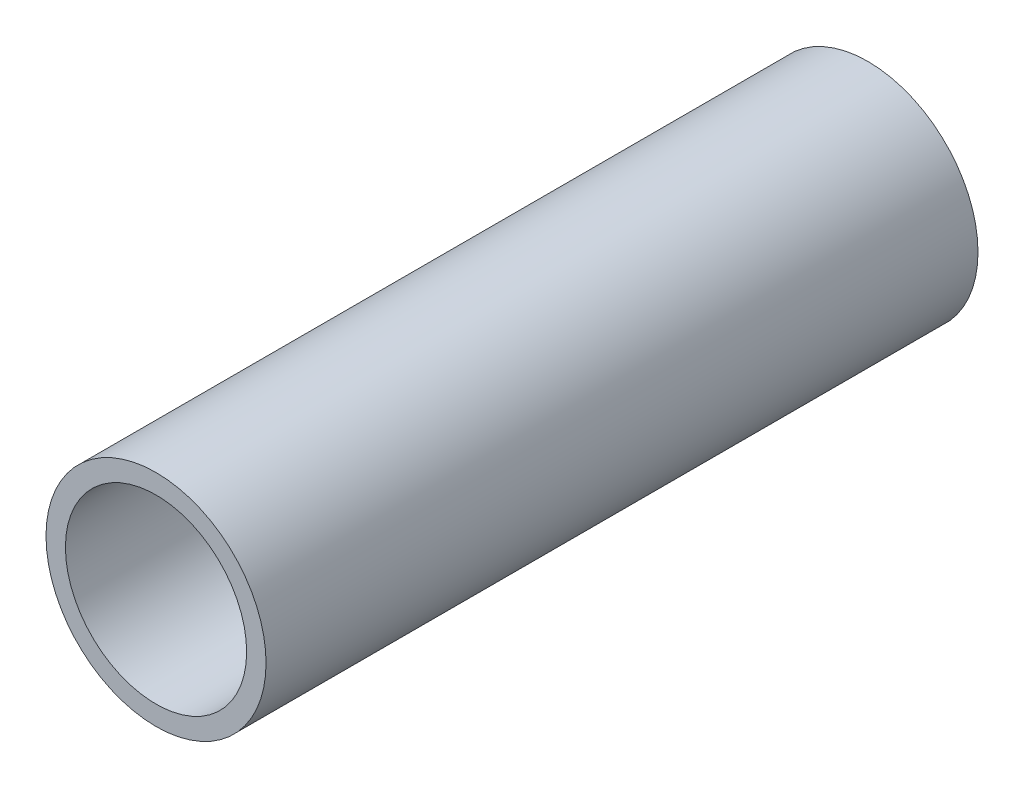
from build123d import *

# Parameters (mm, degrees)
SKETCH1_R           = 17
SKETCH1_R_2         = 14
BOSS_EXTRUDE1_DEPTH = 110


with BuildPart() as part:
    # Sketch1 → Boss-Extrude1 (new body)
    with BuildSketch(Plane.XY):
        with Locations((347.5, -26)):
            Circle(SKETCH1_R)
        with Locations((347.5, -26)):
            Circle(SKETCH1_R_2, mode=Mode.SUBTRACT)
    extrude(amount=-BOSS_EXTRUDE1_DEPTH)


solid = part.part
